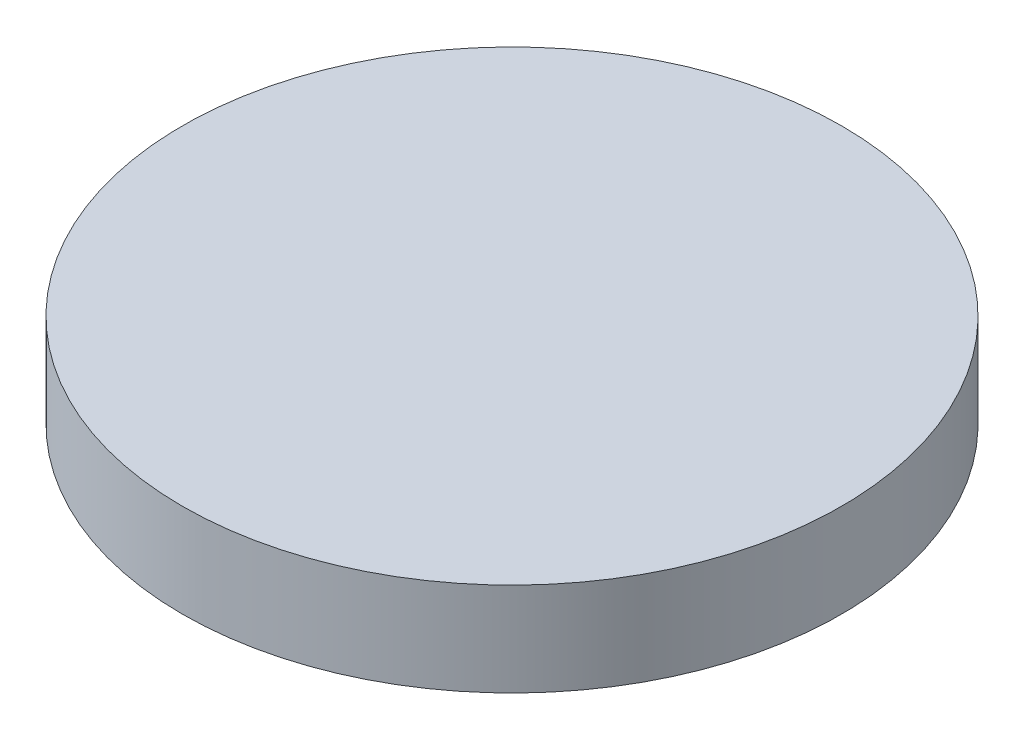
from build123d import *

# Parameters (mm, degrees)
SKETCH1_R           = 1950
BOSS_EXTRUDE1_DEPTH = 276.5


with BuildPart() as part:
    # Sketch1 → Boss-Extrude1 (new body, symmetric)
    with BuildSketch(Plane(origin=(0, 0, 0), x_dir=(1, 0, 0), z_dir=(0, 1, 0))):
        Circle(SKETCH1_R)
    extrude(amount=BOSS_EXTRUDE1_DEPTH, both=True)


solid = part.part
